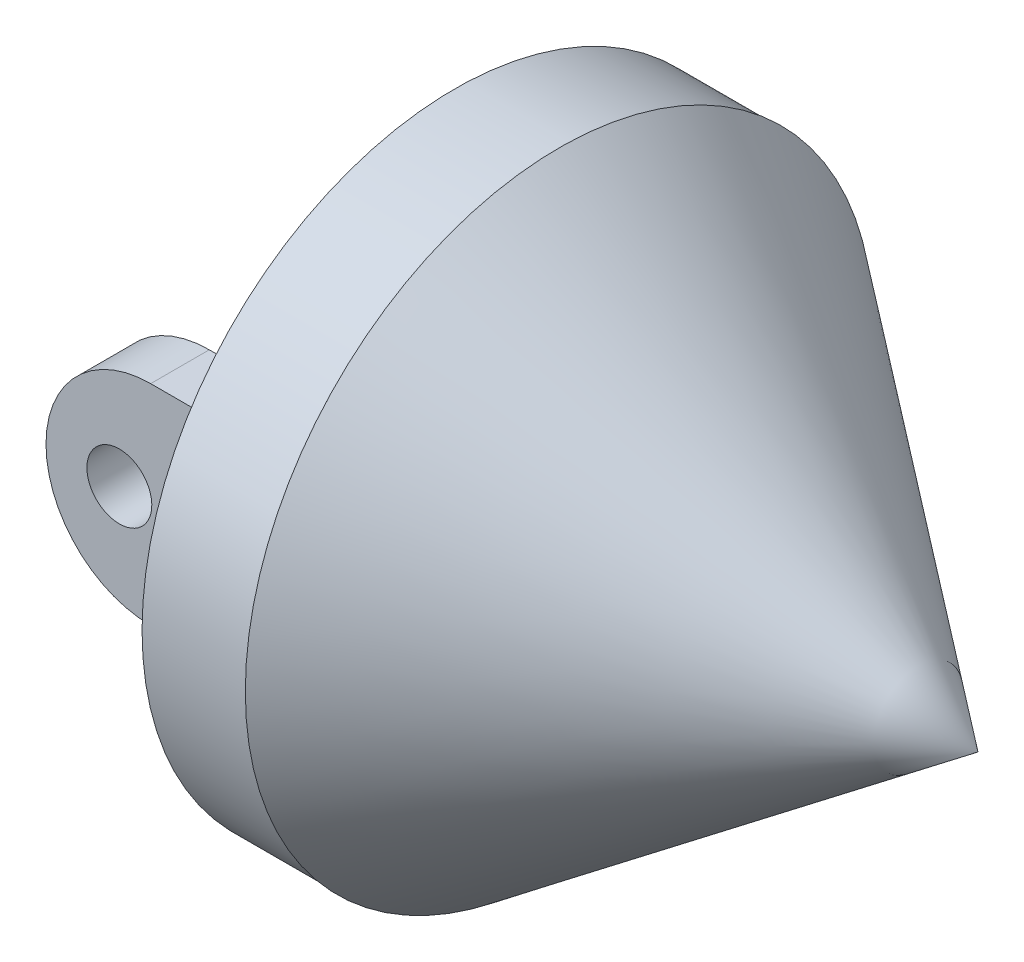
from build123d import *

# Parameters (mm, degrees)
SKETCH3_R                = 14.933526733
BOSS_EXTRUDE2_DEPTH      = 5
SKETCH4_W                = 3.6
SKETCH4_H                = 15
CUT_EXTRUDE1_DEPTH       = 2
CUT_EXTRUDE1_DEPTH_BACK  = 30.620731291
CUT_EXTRUDE4_START       = 4
SKETCH6_W                = 5.202489895
SKETCH6_H                = 21.176797573
CUT_EXTRUDE4_DEPTH       = 34.154759474
SKETCH8_R                = 1
CUT_EXTRUDE6_DEPTH       = 5
SKETCH9_R                = 1
CUT_EXTRUDE9_DEPTH       = 5
SKETCH10_W               = 3.6
SKETCH10_H               = 15
BOSS_EXTRUDE3_DEPTH      = 15
CUT_EXTRUDE10_START      = -5
SKETCH11_W               = 0.8
SKETCH11_H               = 15
CUT_EXTRUDE10_DEPTH      = 12
SKETCH12_R               = 1.55
CUT_EXTRUDE11_DEPTH      = 30.154759474
CUT_EXTRUDE11_DEPTH_BACK = 30.154759474


with BuildPart() as part:
    # Sketch1 → Revolve2 (revolve)
    with BuildSketch(Plane.XY, mode=Mode.PRIVATE) as revolve2_sk:
        Polygon((0, 0), (0, 15), (20, 0), align=None)
    revolve(revolve2_sk.sketch.rotate(Axis((-31.294130364, 0, 0), (1, 0, 0)), 90), axis=Axis((-31.294130364, 0, 0), (1, 0, 0)))

    # Sketch3 → Boss-Extrude2 (add)
    with BuildSketch(Plane(origin=(0, 0, 0), x_dir=(0, 0, -1), z_dir=(1, 0, 0))):
        Circle(SKETCH3_R)
    extrude(amount=-BOSS_EXTRUDE2_DEPTH)

    # Sketch4 → Cut-Extrude1 (cut, two sides)
    with BuildSketch(Plane(origin=(0, 0, -0.886715275), x_dir=(0, 0, -1), z_dir=(1, 0, 0))) as cut_extrude1_sk:
        with Locations((-9.407876673, 0)):
            Rectangle(SKETCH4_W, SKETCH4_H)
    extrude(amount=CUT_EXTRUDE1_DEPTH, mode=Mode.SUBTRACT)
    extrude(cut_extrude1_sk.sketch, amount=-CUT_EXTRUDE1_DEPTH_BACK, mode=Mode.SUBTRACT)

    # Sketch6 → Cut-Extrude4 (cut, through all)
    with BuildSketch(Plane(origin=(0, 0, 0), x_dir=(0, 0, -1), z_dir=(1, 0, 0)).offset(CUT_EXTRUDE4_START)):
        with Locations((-1.119916451, 0.254630833)):
            Rectangle(SKETCH6_W, SKETCH6_H)
    extrude(amount=-CUT_EXTRUDE4_DEPTH, mode=Mode.SUBTRACT)

    # Sketch8 → Cut-Extrude6 (cut)
    with BuildSketch(Plane.XY):
        with Locations((-2.552019749, 6.182563449)):
            Circle(SKETCH8_R)
        with Locations(Location((-2.552019749, -6.182563449, 0), (0, 0, 270))):
            Circle(SKETCH8_R)
    extrude(amount=-CUT_EXTRUDE6_DEPTH, mode=Mode.SUBTRACT)

    # Sketch9 → Cut-Extrude9 (cut)
    with BuildSketch(Plane(origin=(0, 0, 0), x_dir=(0, 0, -1), z_dir=(1, 0, 0))):
        with Locations((3.923175217, -6.295020596)):
            Circle(SKETCH9_R)
        with Locations((3.923175217, 6.295020596)):
            Circle(SKETCH9_R)
    extrude(amount=-CUT_EXTRUDE9_DEPTH, mode=Mode.SUBTRACT)

    # Sketch10 → Boss-Extrude3 (add)
    with BuildSketch(Plane(origin=(0, 0, 0), x_dir=(0, 0, -1), z_dir=(1, 0, 0))):
        with Locations((-8.521161398, 0)):
            Rectangle(SKETCH10_W, SKETCH10_H)
    extrude(amount=-BOSS_EXTRUDE3_DEPTH)

    # Sketch11 → Cut-Extrude10 (cut)
    with BuildSketch(Plane(origin=(0, 0, 0), x_dir=(0, 0, -1), z_dir=(1, 0, 0)).offset(CUT_EXTRUDE10_START)):
        with Locations((-9.921161398, 0)):
            Rectangle(SKETCH11_W, SKETCH11_H)
    extrude(amount=-CUT_EXTRUDE10_DEPTH, mode=Mode.SUBTRACT)

    # Sketch12 → Cut-Extrude11 (cut, two sides)
    with BuildSketch(Plane.XY) as cut_extrude11_sk:
        with BuildLine():
            ThreePointArc((-15, 0), (-13.535533906, 3.535533906), (-10, 5))
            Line((-10, 5), (-5, 5))
            Line((-5, 5), (-5, 9.202194168))
            Line((-5, 9.202194168), (-18.010498555, 9.996270698))
            Line((-18.010498555, 9.996270698), (-16.284245229, -10.269943354))
            Line((-16.284245229, -10.269943354), (-5, -9.308764033))
            Line((-5, -9.308764033), (-5, -5))
            Line((-5, -5), (-10, -5))
            ThreePointArc((-10, -5), (-13.535533906, -3.535533906), (-15, 0))
        make_face()
        with Locations(Location((-11.495940447, 0, 0), (0, 0, 270))):
            Circle(SKETCH12_R)
    extrude(amount=CUT_EXTRUDE11_DEPTH, mode=Mode.SUBTRACT)
    extrude(cut_extrude11_sk.sketch, amount=-CUT_EXTRUDE11_DEPTH_BACK, mode=Mode.SUBTRACT)


solid = part.part
